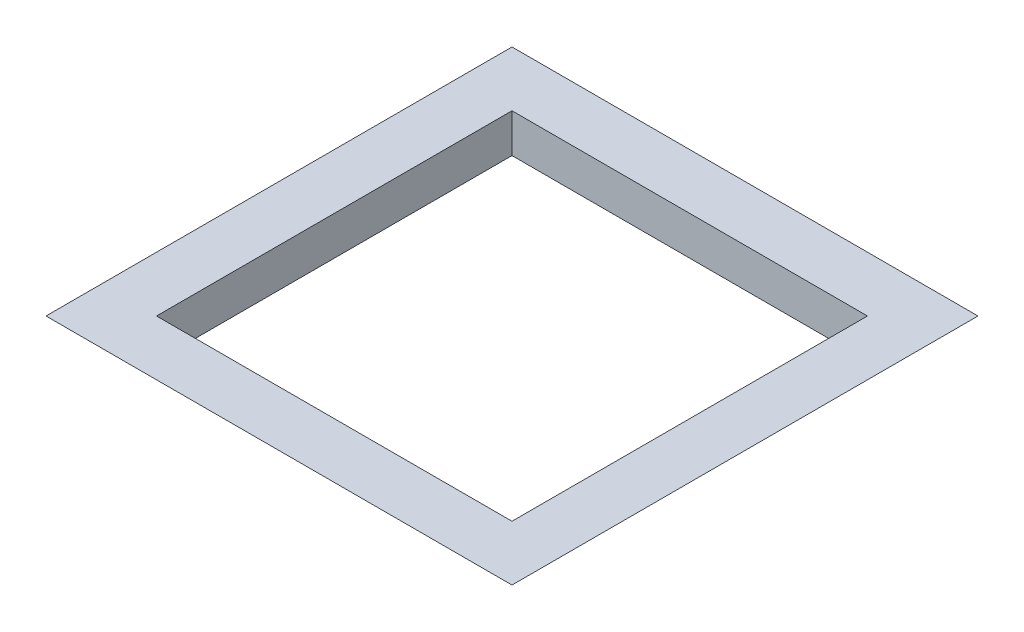
from build123d import *

# Parameters (mm, degrees)
SKETCH1_W           = 130
SKETCH1_H           = 130
BOSS_EXTRUDE1_DEPTH = 13
BOSS_EXTRUDE1_TAPER = -45
SKETCH2_W           = 119
SKETCH2_H           = 119
CUT_EXTRUDE1_DEPTH  = 13


with BuildPart() as part:
    # Sketch1 → Boss-Extrude1 (new body)
    with BuildSketch(Plane(origin=(0, 0, 0), x_dir=(1, 0, 0), z_dir=(0, 1, 0))):
        with Locations((65, 65)):
            Rectangle(SKETCH1_W, SKETCH1_H)
    extrude(amount=BOSS_EXTRUDE1_DEPTH, taper=BOSS_EXTRUDE1_TAPER)

    # Sketch2 → Cut-Extrude1 (cut)
    with BuildSketch(Plane(origin=(0, 13, 0), x_dir=(1, 0, 0), z_dir=(0, 1, 0))):
        with Locations((65, 65)):
            Rectangle(SKETCH2_W, SKETCH2_H)
    extrude(amount=-CUT_EXTRUDE1_DEPTH, mode=Mode.SUBTRACT)


solid = part.part
